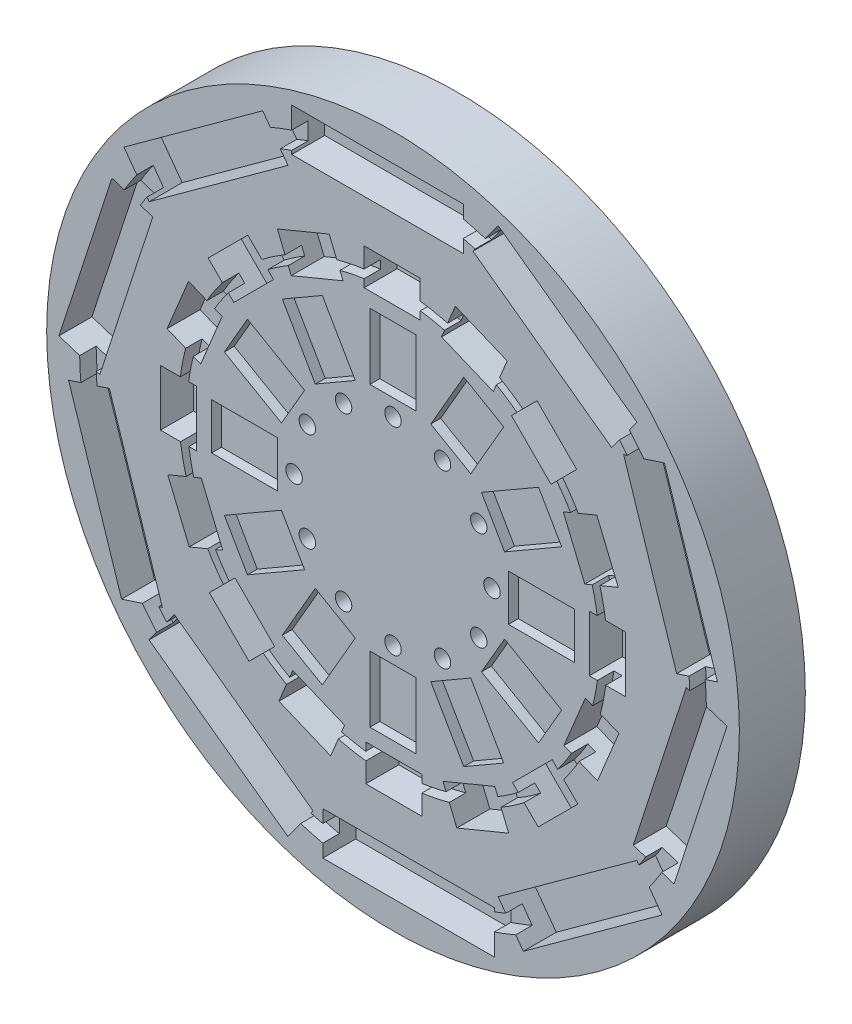
from build123d import *

# Parameters (mm, degrees)
SKETCH1_R           = 105
BOSS_EXTRUDE1_DEPTH = 20
SKETCH2_R           = 2.5
CUT_EXTRUDE1_DEPTH  = 21
SKETCH3_W           = 14
SKETCH3_H           = 20
SKETCH3_W_2         = 20
SKETCH3_H_2         = 14
CUT_EXTRUDE6_DEPTH  = 3
SKETCH7_W           = 17
SKETCH7_H           = 11
SKETCH7_W_2         = 11
SKETCH7_H_2         = 17
CUT_EXTRUDE8_DEPTH  = 10
SKETCH8_R           = 65
SKETCH8_R_2         = 62.5
CUT_EXTRUDE9_DEPTH  = 5
SKETCH9_W           = 52
SKETCH9_H           = 13
CUT_EXTRUDE10_DEPTH = 10
SKETCH10_R          = 95
SKETCH10_R_2        = 90
CUT_EXTRUDE11_DEPTH = 5


with BuildPart() as part:
    # Sketch1 → Boss-Extrude1 (new body)
    with BuildSketch(Plane.XY):
        Circle(SKETCH1_R)
    extrude(amount=BOSS_EXTRUDE1_DEPTH)

    # Sketch2 → Cut-Extrude1 (cut, through all)
    with BuildSketch(Plane.XY.offset(20)):
        with Locations((0, 30)):
            Circle(SKETCH2_R)
        with Locations((15, 25.980762114)):
            Circle(SKETCH2_R)
        with Locations((25.980762114, 15)):
            Circle(SKETCH2_R)
        with Locations((30, 0)):
            Circle(SKETCH2_R)
        with Locations((25.980762114, -15)):
            Circle(SKETCH2_R)
        with Locations((15, -25.980762114)):
            Circle(SKETCH2_R)
        with Locations((0, -30)):
            Circle(SKETCH2_R)
        with Locations((-15, -25.980762114)):
            Circle(SKETCH2_R)
        with Locations((-25.980762114, -15)):
            Circle(SKETCH2_R)
        with Locations((-30, 0)):
            Circle(SKETCH2_R)
        with Locations((-25.980762114, 15)):
            Circle(SKETCH2_R)
        with Locations((-15, 25.980762114)):
            Circle(SKETCH2_R)
    extrude(amount=-CUT_EXTRUDE1_DEPTH, mode=Mode.SUBTRACT)

    # Sketch3 → Cut-Extrude6 (cut)
    with BuildSketch(Plane.XY.offset(20)):
        Polygon((23.562177826, 26.810889132), (33.562177826, 44.131397208), (21.437822174, 51.131397208), (11.437822174, 33.810889132), align=None)
        with Locations((0, 45)):
            Rectangle(SKETCH3_W, SKETCH3_H)
        Polygon((33.810889132, 11.437822174), (51.131397208, 21.437822174), (44.131397208, 33.562177826), (26.810889132, 23.562177826), align=None)
        with Locations((45, 0)):
            Rectangle(SKETCH3_W_2, SKETCH3_H_2)
        Polygon((26.810889132, -23.562177826), (44.131397208, -33.562177826), (51.131397208, -21.437822174), (33.810889132, -11.437822174), align=None)
        Polygon((11.437822174, -33.810889132), (21.437822174, -51.131397208), (33.562177826, -44.131397208), (23.562177826, -26.810889132), align=None)
        with Locations((0, -45)):
            Rectangle(SKETCH3_W, SKETCH3_H)
        Polygon((-23.562177826, -26.810889132), (-33.562177826, -44.131397208), (-21.437822174, -51.131397208), (-11.437822174, -33.810889132), align=None)
        Polygon((-33.810889132, -11.437822174), (-51.131397208, -21.437822174), (-44.131397208, -33.562177826), (-26.810889132, -23.562177826), align=None)
        with Locations((-45, 0)):
            Rectangle(SKETCH3_W_2, SKETCH3_H_2)
        Polygon((-26.810889132, 23.562177826), (-44.131397208, 33.562177826), (-51.131397208, 21.437822174), (-33.810889132, 11.437822174), align=None)
        Polygon((-11.437822174, 33.810889132), (-21.437822174, 51.131397208), (-33.562177826, 44.131397208), (-23.562177826, 26.810889132), align=None)
    extrude(amount=-CUT_EXTRUDE6_DEPTH, mode=Mode.SUBTRACT)

    # Sketch7 → Cut-Extrude8 (cut)
    with BuildSketch(Plane.XY.offset(20)):
        Polygon((30.393407566, 51.812974297), (34.602925322, 61.975649154), (18.896973269, 68.481267505), (14.687455513, 58.318592647), align=None)
        with Locations((-0.248119671, 65)):
            Rectangle(SKETCH7_W, SKETCH7_H)
        Polygon((47.907814018, 36.237892943), (55.685988612, 44.016067536), (43.665173331, 56.036882816), (35.886998738, 48.258708223), align=None)
        Polygon((58.128690072, 15.145920885), (68.29136493, 19.355438641), (61.785746579, 35.061390694), (51.623071722, 30.851872938), align=None)
        with Locations((65, 0.248119671)):
            Rectangle(SKETCH7_W_2, SKETCH7_H_2)
        Polygon((51.812974297, -30.393407566), (61.975649154, -34.602925322), (68.481267505, -18.896973269), (58.318592647, -14.687455513), align=None)
        Polygon((36.237892943, -47.907814018), (44.016067536, -55.685988612), (56.036882816, -43.665173331), (48.258708223, -35.886998738), align=None)
        Polygon((15.145920885, -58.128690072), (19.355438641, -68.29136493), (35.061390694, -61.785746579), (30.851872938, -51.623071722), align=None)
        with Locations((0.248119671, -65)):
            Rectangle(SKETCH7_W, SKETCH7_H)
        Polygon((-30.393407566, -51.812974297), (-34.602925322, -61.975649154), (-18.896973269, -68.481267505), (-14.687455513, -58.318592647), align=None)
        Polygon((-47.907814018, -36.237892943), (-55.685988612, -44.016067536), (-43.665173331, -56.036882816), (-35.886998738, -48.258708223), align=None)
        Polygon((-58.128690072, -15.145920885), (-68.29136493, -19.355438641), (-61.785746579, -35.061390694), (-51.623071722, -30.851872938), align=None)
        with Locations((-65, -0.248119671)):
            Rectangle(SKETCH7_W_2, SKETCH7_H_2)
        Polygon((-51.812974297, 30.393407566), (-61.975649154, 34.602925322), (-68.481267505, 18.896973269), (-58.318592647, 14.687455513), align=None)
        Polygon((-36.237892943, 47.907814018), (-44.016067536, 55.685988612), (-56.036882816, 43.665173331), (-48.258708223, 35.886998738), align=None)
        Polygon((-15.145920885, 58.128690072), (-19.355438641, 68.29136493), (-35.061390694, 61.785746579), (-30.851872938, 51.623071722), align=None)
    extrude(amount=-CUT_EXTRUDE8_DEPTH, mode=Mode.SUBTRACT)

    # Sketch8 → Cut-Extrude9 (cut)
    with BuildSketch(Plane.XY.offset(20)):
        Circle(SKETCH8_R)
        Circle(SKETCH8_R_2, mode=Mode.SUBTRACT)
    extrude(amount=-CUT_EXTRUDE9_DEPTH, mode=Mode.SUBTRACT)

    # Sketch9 → Cut-Extrude10 (cut)
    with BuildSketch(Plane.XY.offset(20)):
        Polygon((66.308227073, 55.035929196), (73.949435353, 65.553150123), (31.880551646, 96.117983242), (24.239343366, 85.600762315), align=None)
        with Locations((-4.704824958, 90)):
            Rectangle(SKETCH9_W, SKETCH9_H)
        Polygon((85.993790097, 5.550004041), (98.357524809, 9.567224968), (82.288641101, 59.022163816), (69.924906389, 55.004942889), align=None)
        Polygon((72.832648125, -46.055834019), (85.196382836, -50.073054946), (101.265266544, -0.618116099), (88.901531832, 3.399104828), align=None)
        Polygon((31.85191006, -80.069908865), (39.493118339, -90.587129792), (81.562002047, -60.022296672), (73.920793767, -49.505075746), align=None)
        with Locations((4.704824958, -90)):
            Rectangle(SKETCH9_W, SKETCH9_H)
        Polygon((-66.308227073, -55.035929196), (-73.949435353, -65.553150123), (-31.880551646, -96.117983242), (-24.239343366, -85.600762315), align=None)
        Polygon((-85.993790097, -5.550004041), (-98.357524809, -9.567224968), (-82.288641101, -59.022163816), (-69.924906389, -55.004942889), align=None)
        Polygon((-72.832648125, 46.055834019), (-85.196382836, 50.073054946), (-101.265266544, 0.618116099), (-88.901531832, -3.399104828), align=None)
        Polygon((-31.85191006, 80.069908865), (-39.493118339, 90.587129792), (-81.562002047, 60.022296672), (-73.920793767, 49.505075746), align=None)
    extrude(amount=-CUT_EXTRUDE10_DEPTH, mode=Mode.SUBTRACT)

    # Sketch10 → Cut-Extrude11 (cut)
    with BuildSketch(Plane.XY.offset(20)):
        Circle(SKETCH10_R)
        Circle(SKETCH10_R_2, mode=Mode.SUBTRACT)
    extrude(amount=-CUT_EXTRUDE11_DEPTH, mode=Mode.SUBTRACT)


solid = part.part
